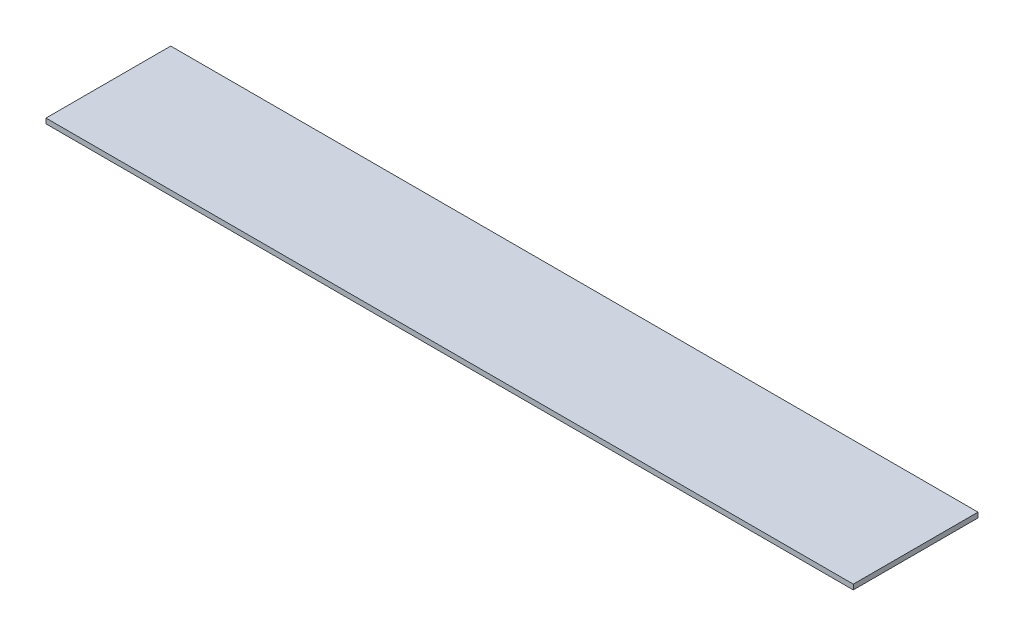
from build123d import *

# Parameters (mm, degrees)
SKETCH1_W           = 1016
SKETCH1_H           = 156.954128314
BOSS_EXTRUDE1_DEPTH = 6.35


with BuildPart() as part:
    # Sketch1 → Boss-Extrude1 (new body)
    with BuildSketch(Plane(origin=(0, 0, 0), x_dir=(1, 0, 0), z_dir=(0, 1, 0))):
        with Locations((508, 27.943832992)):
            Rectangle(SKETCH1_W, SKETCH1_H)
    extrude(amount=BOSS_EXTRUDE1_DEPTH)


solid = part.part
